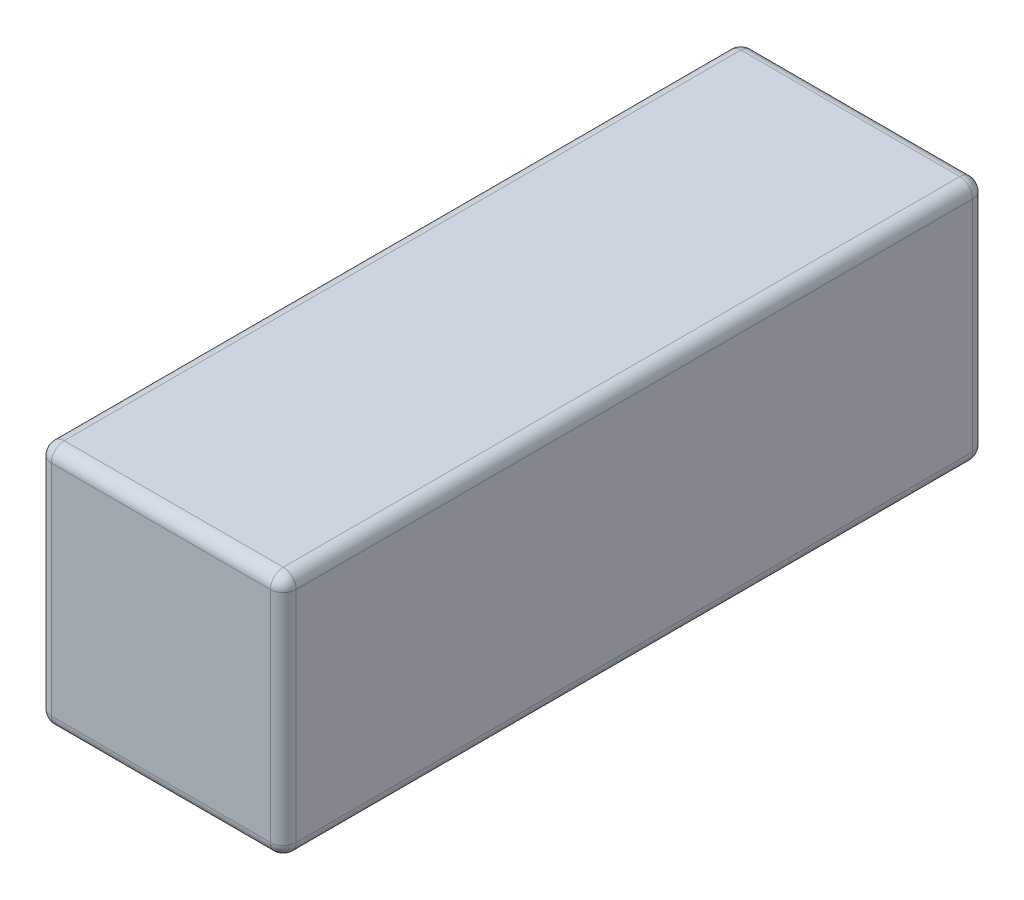
from build123d import *

# Parameters (mm, degrees)
SKETCH1_W           = 48.26
SKETCH1_H           = 48.26
BOSS_EXTRUDE1_DEPTH = 138.43
FILLET1_R           = 2.54
FILLET2_R           = 2.54
SCALE1_SCALE        = 0.06


with BuildPart() as part:
    # Sketch1 → Boss-Extrude1 (new body)
    with BuildSketch(Plane.XY):
        Rectangle(SKETCH1_W, SKETCH1_H)
    extrude(amount=BOSS_EXTRUDE1_DEPTH)

    # Fillet1
    fillet1_edges = [part.edges().sort_by_distance(p)[0] for p in [
        (-24.13, 24.13, 69.215),
        (24.13, 24.13, 69.215),
        (24.13, -24.13, 69.215),
        (-24.13, -24.13, 69.215),
    ]]
    fillet(fillet1_edges, radius=FILLET1_R)

    # Fillet2
    fillet2_edges = [part.edges().sort_by_distance(p)[0] for p in [
        (0, -24.13, 0),
        (0, -24.13, 138.43),
        (-24.13, 0, 0),
        (0, 24.13, 0),
        (24.13, 0, 0),
        (-23.386051224, 23.386051224, 0),
        (23.386051224, 23.386051224, 0),
        (23.386051224, -23.386051224, 0),
        (-23.386051224, -23.386051224, 0),
        (-24.13, 0, 138.43),
        (24.13, 0, 138.43),
        (0, 24.13, 138.43),
        (-23.386051224, 23.386051224, 138.43),
        (23.386051224, 23.386051224, 138.43),
        (23.386051224, -23.386051224, 138.43),
        (-23.386051224, -23.386051224, 138.43),
    ]]
    fillet(fillet2_edges, radius=FILLET2_R)


with BuildPart() as part_1:
    # Scale1: scaled about (0, 0, 69.215)
    add(part.part.scale(SCALE1_SCALE).moved(Location((0, 0, 65.0621))))


solid = part_1.part
